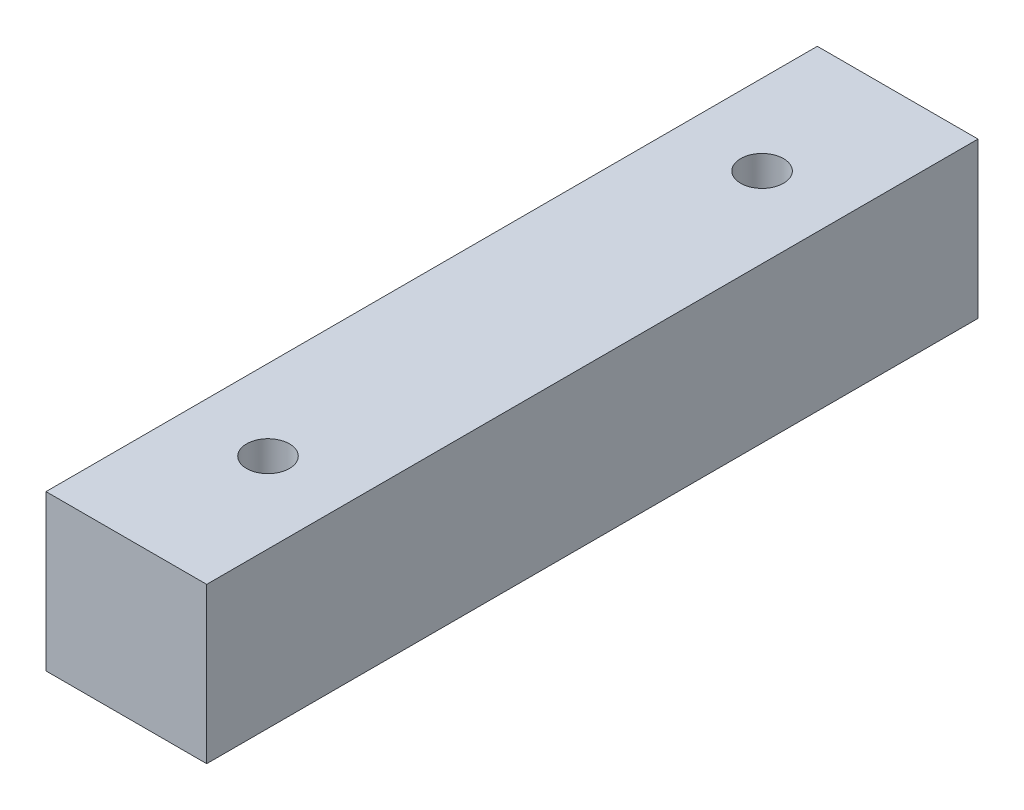
from build123d import *

# Parameters (mm, degrees)
SKETCH2_W           = 13200
SKETCH2_H           = 2700
BOSS_EXTRUDE1_DEPTH = 1500
SKETCH4_R           = 400
SKETCH5_W           = 3000
SKETCH5_H           = 13200
BOSS_EXTRUDE2_DEPTH = 200
SKETCH6_W           = 3000
SKETCH6_H           = 2900
BOSS_EXTRUDE3_DEPTH = 200
SKETCH7_W           = 3000
SKETCH7_H           = 2900
BOSS_EXTRUDE4_DEPTH = 1000


with BuildPart() as part:
    # Sketch2 → Boss-Extrude1 (new body, symmetric)
    with BuildSketch(Plane(origin=(0, 0, 0), x_dir=(0, 0, -1), z_dir=(1, 0, 0))):
        Rectangle(SKETCH2_W, SKETCH2_H)
    extrude(amount=BOSS_EXTRUDE1_DEPTH, both=True)

    # Cut-Sweep1: sweep along a path in Sketch3
    with BuildLine(Plane(origin=(0, 0, 0), x_dir=(0, 0, -1), z_dir=(1, 0, 0))) as cut_sweep1_path:
        Line((-4155.24, 1658.848413631), (-4155.24, -299.514296906))
        Line((-4155.24, -299.514296906), (5068.703486095, -299.514296906))
        Line((5068.703486095, -299.514296906), (5068.703486095, 1658.848413631))
    # Sketch4 → Cut-Sweep1 (sweep, cut)
    with BuildSketch(Plane(origin=(0, 1658.848413631, 4155.24), x_dir=(-1, 0, 0), z_dir=(0, -1, 0))):
        Circle(SKETCH4_R)
    sweep(path=cut_sweep1_path.line, transition=Transition.RIGHT, mode=Mode.SUBTRACT)

    # Sketch5 → Boss-Extrude2 (add)
    with BuildSketch(Plane.XZ.offset(1350)):
        Rectangle(SKETCH5_W, SKETCH5_H)
    extrude(amount=BOSS_EXTRUDE2_DEPTH)

    # Sketch6 → Boss-Extrude3 (add)
    with BuildSketch(Plane.XY.offset(6600)):
        with Locations((0, -100)):
            Rectangle(SKETCH6_W, SKETCH6_H)
    extrude(amount=BOSS_EXTRUDE3_DEPTH)

    # Sketch7 → Boss-Extrude4 (add)
    with BuildSketch(Plane(origin=(0, 0, -6600), x_dir=(-1, 0, 0), z_dir=(0, 0, -1))):
        with Locations((0, -100)):
            Rectangle(SKETCH7_W, SKETCH7_H)
    extrude(amount=BOSS_EXTRUDE4_DEPTH)


solid = part.part
